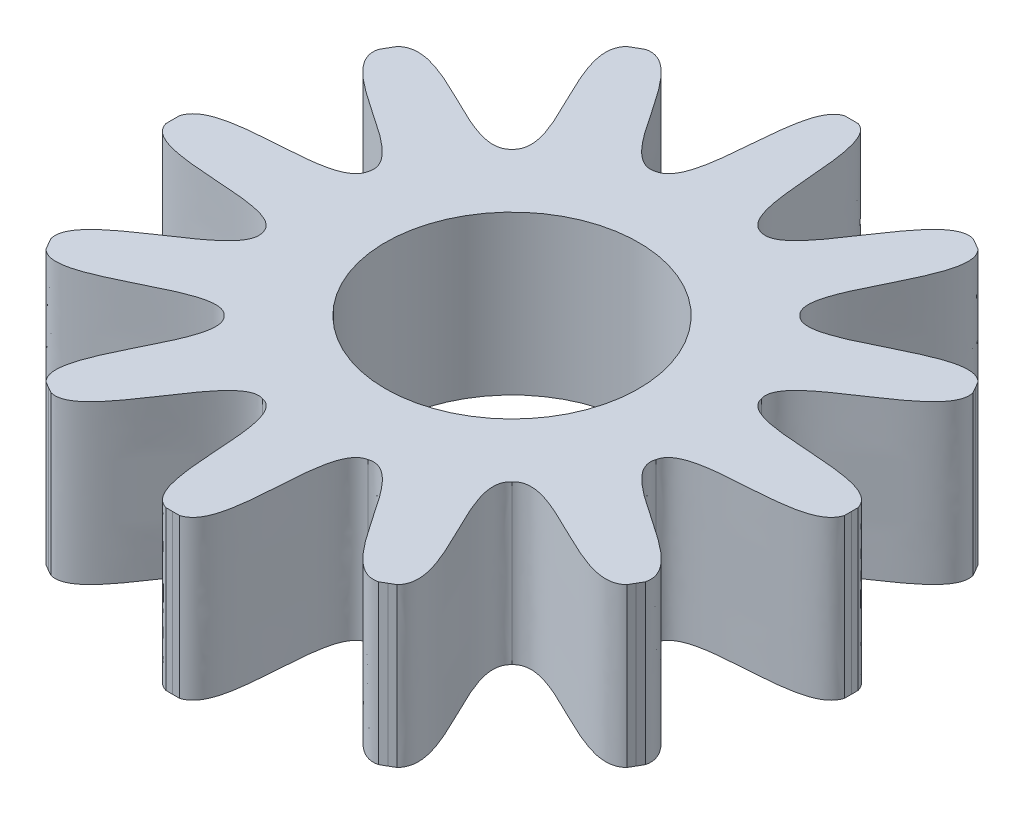
from build123d import *

# Parameters (mm, degrees)
BOSS_EXTRUDE1_DEPTH = 0.35
SKETCH2_R           = 0.28
CUT_EXTRUDE1_DEPTH  = 1.3500001


with BuildPart() as part:
    # Sketch1 → Boss-Extrude1 (new body)
    with BuildSketch(Plane(origin=(0, 0, 0), x_dir=(1, 0, 0), z_dir=(0, 1, 0))):
        with BuildLine():
            Line((0, 0.75), (0.01499925, 0.74985))
            add(Edge.make_bspline(
                [(0.01499925, 0.74985), (0.089770208, 0.726526589), (0.037536283, 0.45058181), (0.11646857, 0.434666622)],
                knots=[0, 0, 0, 0, 1, 1, 1, 1], degree=3))
            add(Edge.make_bspline(
                [(0.361935268, 0.656888774), (0.27667218, 0.679442999), (0.19278353, 0.408983436), (0.11646857, 0.434666622)],
                knots=[0, 0, 0, 0, 1, 1, 1, 1], degree=3))
            Line((0.361935268, 0.656888774), (0.375, 0.649519053))
            Line((0.375, 0.649519053), (0.387914732, 0.641889524))
            add(Edge.make_bspline(
                [(0.387914732, 0.641889524), (0.450078807, 0.579326636), (0.25779828, 0.371447153), (0.318198052, 0.318198052)],
                knots=[0, 0, 0, 0, 1, 1, 1, 1], degree=3))
            add(Edge.make_bspline(
                [(0.641889524, 0.387914732), (0.579326636, 0.450078807), (0.371447153, 0.25779828), (0.318198052, 0.318198052)],
                knots=[0, 0, 0, 0, 1, 1, 1, 1], degree=3))
            Line((0.641889524, 0.387914732), (0.649519053, 0.375))
            Line((0.649519053, 0.375), (0.656888774, 0.361935268))
            add(Edge.make_bspline(
                [(0.656888774, 0.361935268), (0.679442999, 0.27667218), (0.408983436, 0.19278353), (0.434666622, 0.11646857)],
                knots=[0, 0, 0, 0, 1, 1, 1, 1], degree=3))
            add(Edge.make_bspline(
                [(0.74985, 0.01499925), (0.726750987, 0.100116363), (0.45058181, 0.037536283), (0.434666622, 0.11646857)],
                knots=[0, 0, 0, 0, 1, 1, 1, 1], degree=3))
            Line((0.74985, 0.01499925), (0.75, 0))
            Line((0.75, 0), (0.74985, -0.01499925))
            add(Edge.make_bspline(
                [(0.74985, -0.01499925), (0.726750987, -0.100116363), (0.45058181, -0.037536283), (0.434666622, -0.11646857)],
                knots=[0, 0, 0, 0, 1, 1, 1, 1], degree=3))
            add(Edge.make_bspline(
                [(0.656888774, -0.361935268), (0.679442999, -0.27667218), (0.408983436, -0.19278353), (0.434666622, -0.11646857)],
                knots=[0, 0, 0, 0, 1, 1, 1, 1], degree=3))
            Line((0.656888774, -0.361935268), (0.649519053, -0.375))
            Line((0.649519053, -0.375), (0.641889524, -0.387914732))
            add(Edge.make_bspline(
                [(0.641889524, -0.387914732), (0.579326636, -0.450078807), (0.371447153, -0.25779828), (0.318198052, -0.318198052)],
                knots=[0, 0, 0, 0, 1, 1, 1, 1], degree=3))
            add(Edge.make_bspline(
                [(0.387914732, -0.641889524), (0.450078807, -0.579326636), (0.25779828, -0.371447153), (0.318198052, -0.318198052)],
                knots=[0, 0, 0, 0, 1, 1, 1, 1], degree=3))
            Line((0.387914732, -0.641889524), (0.375, -0.649519053))
            Line((0.375, -0.649519053), (0.361935268, -0.656888774))
            add(Edge.make_bspline(
                [(0.361935268, -0.656888774), (0.27667218, -0.679442999), (0.19278353, -0.408983436), (0.11646857, -0.434666622)],
                knots=[0, 0, 0, 0, 1, 1, 1, 1], degree=3))
            add(Edge.make_bspline(
                [(0.01499925, -0.74985), (0.100116363, -0.726750987), (0.037536283, -0.45058181), (0.11646857, -0.434666622)],
                knots=[0, 0, 0, 0, 1, 1, 1, 1], degree=3))
            Line((0.01499925, -0.74985), (0, -0.75))
            Line((0, -0.75), (-0.01499925, -0.74985))
            add(Edge.make_bspline(
                [(-0.01499925, -0.74985), (-0.100116363, -0.726750987), (-0.037536283, -0.45058181), (-0.11646857, -0.434666622)],
                knots=[0, 0, 0, 0, 1, 1, 1, 1], degree=3))
            add(Edge.make_bspline(
                [(-0.361935268, -0.656888774), (-0.27667218, -0.679442999), (-0.19278353, -0.408983436), (-0.11646857, -0.434666622)],
                knots=[0, 0, 0, 0, 1, 1, 1, 1], degree=3))
            Line((-0.361935268, -0.656888774), (-0.375, -0.649519053))
            Line((-0.375, -0.649519053), (-0.387914732, -0.641889524))
            add(Edge.make_bspline(
                [(-0.387914732, -0.641889524), (-0.450078807, -0.579326636), (-0.25779828, -0.371447153), (-0.318198052, -0.318198052)],
                knots=[0, 0, 0, 0, 1, 1, 1, 1], degree=3))
            add(Edge.make_bspline(
                [(-0.641889524, -0.387914732), (-0.579326636, -0.450078807), (-0.371447153, -0.25779828), (-0.318198052, -0.318198052)],
                knots=[0, 0, 0, 0, 1, 1, 1, 1], degree=3))
            Line((-0.641889524, -0.387914732), (-0.649519053, -0.375))
            Line((-0.649519053, -0.375), (-0.656888774, -0.361935268))
            add(Edge.make_bspline(
                [(-0.656888774, -0.361935268), (-0.679442999, -0.27667218), (-0.408983436, -0.19278353), (-0.434666622, -0.11646857)],
                knots=[0, 0, 0, 0, 1, 1, 1, 1], degree=3))
            add(Edge.make_bspline(
                [(-0.74985, -0.01499925), (-0.726750987, -0.100116363), (-0.45058181, -0.037536283), (-0.434666622, -0.11646857)],
                knots=[0, 0, 0, 0, 1, 1, 1, 1], degree=3))
            Line((-0.74985, -0.01499925), (-0.75, 0))
            Line((-0.75, 0), (-0.74985, 0.01499925))
            add(Edge.make_bspline(
                [(-0.74985, 0.01499925), (-0.726750987, 0.100116363), (-0.45058181, 0.037536283), (-0.434666622, 0.11646857)],
                knots=[0, 0, 0, 0, 1, 1, 1, 1], degree=3))
            add(Edge.make_bspline(
                [(-0.656888774, 0.361935268), (-0.679442999, 0.27667218), (-0.408983436, 0.19278353), (-0.434666622, 0.11646857)],
                knots=[0, 0, 0, 0, 1, 1, 1, 1], degree=3))
            Line((-0.656888774, 0.361935268), (-0.649519053, 0.375))
            Line((-0.649519053, 0.375), (-0.641889524, 0.387914732))
            add(Edge.make_bspline(
                [(-0.641889524, 0.387914732), (-0.579326636, 0.450078807), (-0.371447153, 0.25779828), (-0.318198052, 0.318198052)],
                knots=[0, 0, 0, 0, 1, 1, 1, 1], degree=3))
            add(Edge.make_bspline(
                [(-0.387914732, 0.641889524), (-0.450078807, 0.579326636), (-0.25779828, 0.371447153), (-0.318198052, 0.318198052)],
                knots=[0, 0, 0, 0, 1, 1, 1, 1], degree=3))
            Line((-0.387914732, 0.641889524), (-0.375, 0.649519053))
            Line((-0.375, 0.649519053), (-0.361935268, 0.656888774))
            add(Edge.make_bspline(
                [(-0.361935268, 0.656888774), (-0.27667218, 0.679442999), (-0.19278353, 0.408983436), (-0.11646857, 0.434666622)],
                knots=[0, 0, 0, 0, 1, 1, 1, 1], degree=3))
            add(Edge.make_bspline(
                [(-0.01499925, 0.74985), (-0.089770208, 0.726526589), (-0.037536283, 0.45058181), (-0.11646857, 0.434666622)],
                knots=[0, 0, 0, 0, 1, 1, 1, 1], degree=3))
            Line((-0.01499925, 0.74985), (0, 0.75))
        make_face()
    extrude(amount=BOSS_EXTRUDE1_DEPTH)

    # Sketch2 → Cut-Extrude1 (cut, through all)
    with BuildSketch(Plane(origin=(0, 0, 0), x_dir=(1, 0, 0), z_dir=(0, 1, 0))):
        Circle(SKETCH2_R)
    extrude(amount=CUT_EXTRUDE1_DEPTH, mode=Mode.SUBTRACT)


solid = part.part
